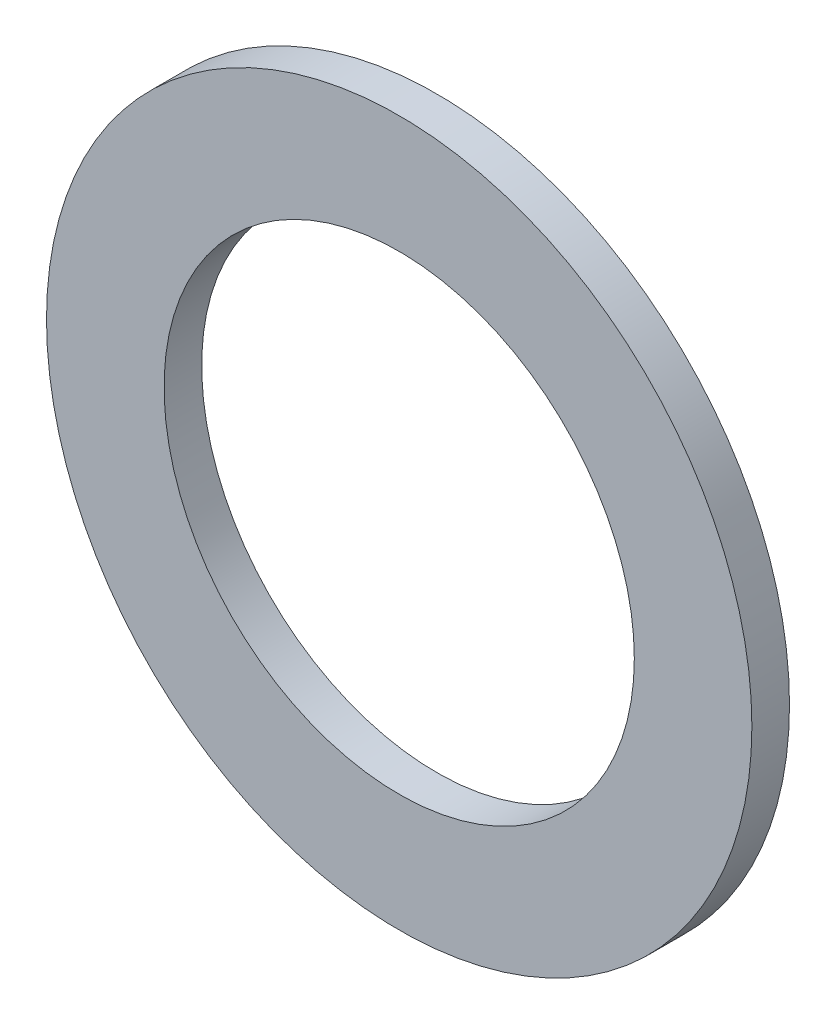
from build123d import *

# Parameters (mm, degrees)
SKETCH3_R           = 2.38125
SKETCH3_R_2         = 1.5875
BOSS_EXTRUDE1_DEPTH = 0.127


with BuildPart() as part:
    # Sketch3 → Boss-Extrude1 (new body, symmetric)
    with BuildSketch(Plane.XY):
        Circle(SKETCH3_R)
        Circle(SKETCH3_R_2, mode=Mode.SUBTRACT)
    extrude(amount=BOSS_EXTRUDE1_DEPTH, both=True)


solid = part.part
